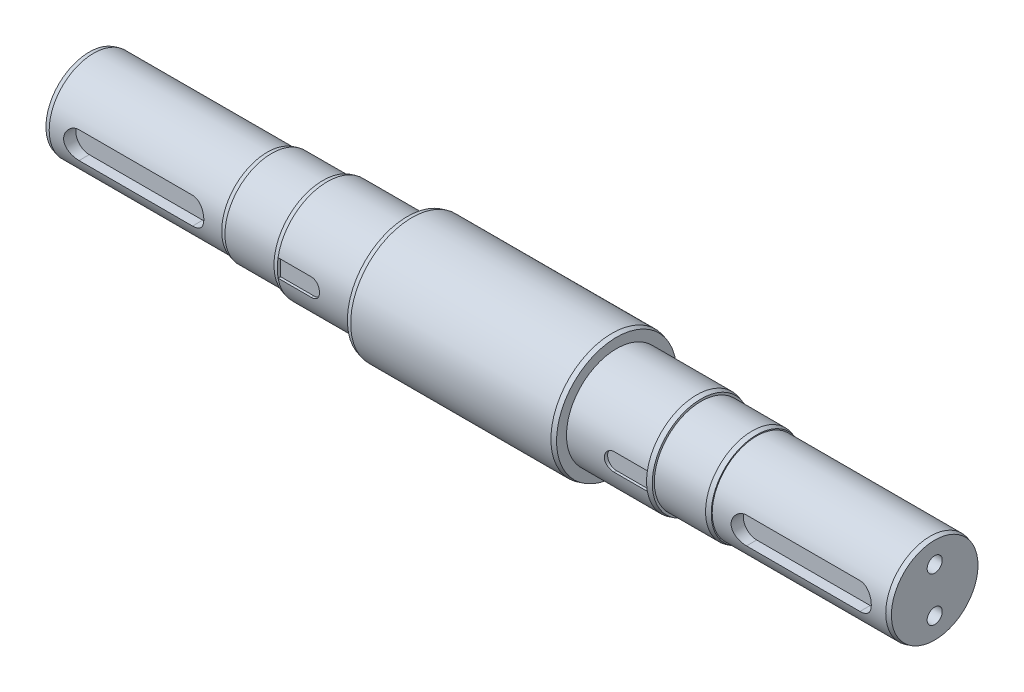
from build123d import *

# Parameters (mm, degrees)
FASE1_SIZE                      = 0.535898385
FASE1_SIZE2                     = 2
FASE1_EDGE_2_SIZE               = 2
FASE1_EDGE_2_SIZE2              = 0.535898385
FASE1_EDGE_3_SIZE               = 2
FASE1_EDGE_3_SIZE2              = 0.535898385
SCHNITT_LINEAR_AUSTRAGEN1_DEPTH = 5.5
M8_GEWINDEBOHRUNG1_D            = 6.8
M8_GEWINDEBOHRUNG1_DEPTH        = 20
M8_GEWINDEBOHRUNG1_TIP          = 2.042926105
FASE2_SIZE                      = 2
FASE2_SIZE2                     = 0.535898385
SCHNITT_LINEAR_AUSTRAGEN2_DEPTH = 1.5


with BuildPart() as part:
    # Skizze1 → Rotation1 (revolve)
    with BuildSketch(Plane.XY, mode=Mode.PRIVATE) as rotation1_sk:
        Polygon((-85, 22.5), (-70, 22.5), (-47, 22.5), (-47, 27.5), (0, 27.5), (0, 0), (-190, 0), (-190, 20), (-110, 20), (-110, 21), (-85, 21), align=None)
    revolve(rotation1_sk.sketch.rotate(Axis((-55.076928245, 0, 0), (1, 0, 0)), 90), axis=Axis((-55.076928245, 0, 0), (1, 0, 0)))  # turned: the seam where the file's is

    # Fase1
    fase1_edges = [part.edges().sort_by_distance(p)[0] for p in [
        (-47, 0, -27.5),
    ]]
    fase1_side = [part.faces().sort_by_distance(p)[0] for p in [
        (-47, 0, -23.277817459),
    ]]
    chamfer(fase1_edges, length=FASE1_SIZE, length2=FASE1_SIZE2, reference=fase1_side[0])

    # Fase1 edge 2
    fase1_edge_2_edges = [part.edges().sort_by_distance(p)[0] for p in [
        (-85, 0, -22.5),
    ]]
    fase1_edge_2_side = [part.faces().sort_by_distance(p)[0] for p in [
        (-66, 0, -22.5),
    ]]
    chamfer(fase1_edge_2_edges, length=FASE1_EDGE_2_SIZE, length2=FASE1_EDGE_2_SIZE2, reference=fase1_edge_2_side[0])

    # Fase1 edge 3
    fase1_edge_3_edges = [part.edges().sort_by_distance(p)[0] for p in [
        (-110, 0, -21),
    ]]
    fase1_edge_3_side = [part.faces().sort_by_distance(p)[0] for p in [
        (-97.5, 0, -21),
    ]]
    chamfer(fase1_edge_3_edges, length=FASE1_EDGE_3_SIZE, length2=FASE1_EDGE_3_SIZE2, reference=fase1_edge_3_side[0])

    # Skizze2 → Schnitt-Linear austragen1 (cut)
    with BuildSketch(Plane.XY.offset(20)):
        with BuildLine():
            Line((-175.5, 6), (-124.5, 6))
            ThreePointArc((-124.5, 6), (-118.5, 0), (-124.5, -6))
            Line((-124.5, -6), (-175.5, -6))
            ThreePointArc((-175.5, -6), (-181.5, 0), (-175.5, 6))
        make_face()
    extrude(amount=-SCHNITT_LINEAR_AUSTRAGEN1_DEPTH, mode=Mode.SUBTRACT)

    # M8 Gewindebohrung1
    with Locations(Plane.ZY.offset(190)):
        with Locations((0, 10), (0, -10)):
            Hole(M8_GEWINDEBOHRUNG1_D / 2, depth=M8_GEWINDEBOHRUNG1_DEPTH)
            with Locations((0, 0, -(M8_GEWINDEBOHRUNG1_DEPTH + M8_GEWINDEBOHRUNG1_TIP / 2))):  # 118° drill point
                Cone(0, M8_GEWINDEBOHRUNG1_D / 2, M8_GEWINDEBOHRUNG1_TIP, mode=Mode.SUBTRACT)

    # Fase2
    fase2_edges = [part.edges().sort_by_distance(p)[0] for p in [
        (-190, 0, -20),
    ]]
    fase2_side = [part.faces().sort_by_distance(p)[0] for p in [
        (-150, 0, -20),
    ]]
    chamfer(fase2_edges, length=FASE2_SIZE, length2=FASE2_SIZE2, reference=fase2_side[0])

    # Skizze8 → Schnitt-Linear austragen2 (cut)
    with BuildSketch(Plane.XY.offset(22.5)):
        with BuildLine():
            Line((-83, 4), (-68, 4))
            ThreePointArc((-68, 4), (-64, 0), (-68, -4))
            Line((-68, -4), (-83, -4))
            Line((-83, -4), (-83, 4))
        make_face()
    extrude(amount=-SCHNITT_LINEAR_AUSTRAGEN2_DEPTH, mode=Mode.SUBTRACT)

    # Spiegeln1: part across plane


with BuildPart() as part_1:
    add(part.part)
    add(part.part.mirror(Plane.ZY))


solid = part_1.part
